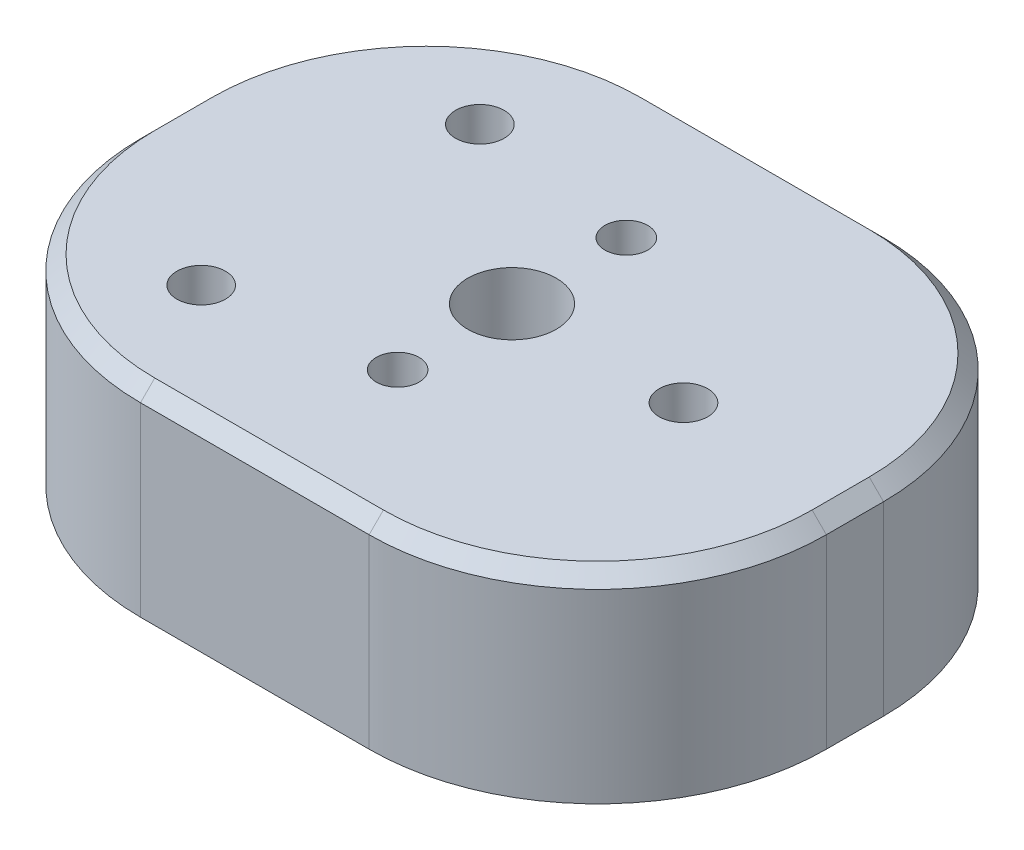
from build123d import *

# Parameters (mm, degrees)
SKETCH1_W           = 48
SKETCH1_H           = 36
SKETCH1_R           = 1.7
BOSS_EXTRUDE1_DEPTH = 14
SKETCH2_R           = 1.5
SKETCH2_R_2         = 3.1
CUT_EXTRUDE3_DEPTH  = 15
SKETCH5_R           = 15
CUT_EXTRUDE4_DEPTH  = 3
SKETCH7_R           = 4.75
CUT_EXTRUDE5_DEPTH  = 6
FILLET1_R           = 16
FILLET2_R           = 16
FILLET3_R           = 0.5
CHAMFER2_SIZE       = 1


with BuildPart() as part:
    # Sketch1 → Boss-Extrude1 (new body)
    with BuildSketch(Plane(origin=(0, 0, 0), x_dir=(1, 0, 0), z_dir=(0, 1, 0))):
        Rectangle(SKETCH1_W, SKETCH1_H)
        with Locations((-12, 9.75)):
            Circle(SKETCH1_R, mode=Mode.SUBTRACT)
        with Locations((-12, -9.75)):
            Circle(SKETCH1_R, mode=Mode.SUBTRACT)
        with Locations((12, 0)):
            Circle(SKETCH1_R, mode=Mode.SUBTRACT)
    extrude(amount=BOSS_EXTRUDE1_DEPTH)

    # Sketch2 → Cut-Extrude3 (cut, through all)
    with BuildSketch(Plane.XZ):
        with Locations((0, 8)):
            Circle(SKETCH2_R)
        with Locations((0, -8)):
            Circle(SKETCH2_R)
        Circle(SKETCH2_R_2)
    extrude(amount=-CUT_EXTRUDE3_DEPTH, mode=Mode.SUBTRACT)

    # Sketch5 → Cut-Extrude4 (cut)
    with BuildSketch(Plane.XZ):
        Circle(SKETCH5_R)
    extrude(amount=-CUT_EXTRUDE4_DEPTH, mode=Mode.SUBTRACT)

    # Sketch7 → Cut-Extrude5 (cut)
    with BuildSketch(Plane.XZ):
        with Locations((12, 0)):
            Circle(SKETCH7_R)
        with Locations((-12, 9.75)):
            Circle(SKETCH7_R)
        with Locations((-12, -9.75)):
            Circle(SKETCH7_R)
    extrude(amount=-CUT_EXTRUDE5_DEPTH, mode=Mode.SUBTRACT)

    # Fillet1
    fillet1_edges = [part.edges().sort_by_distance(p)[0] for p in [
        (24, 7, 18),
        (24, 7, -18),
    ]]
    fillet(fillet1_edges, radius=FILLET1_R)

    # Fillet2
    fillet2_edges = [part.edges().sort_by_distance(p)[0] for p in [
        (-24, 7, 18),
        (-24, 7, -18),
    ]]
    fillet(fillet2_edges, radius=FILLET2_R)

    # Fillet3
    fillet3_edges = [part.edges().sort_by_distance(p)[0] for p in [
        (5.27456542, 0, -14.042042573),
        (5.27456542, 0, 14.042042573),
        (-15, 0, 0),
        (16.13087492, 0, 2.344860848),
        (-15.686541501, 0, 12.745314969),
        (-15.686541501, 0, -12.745314969),
    ]]
    fillet(fillet3_edges, radius=FILLET3_R)

    # Chamfer2
    chamfer2_edges = [part.edges().sort_by_distance(p)[0] for p in [
        (0, 14, -18),
        (19.313708499, 14, -13.313708499),
        (19.313708499, 14, 13.313708499),
        (0, 14, 18),
        (-24, 14, 0),
        (-19.313708499, 14, -13.313708499),
        (-19.313708499, 14, 13.313708499),
        (24, 14, 0),
    ]]
    chamfer(chamfer2_edges, length=CHAMFER2_SIZE)


solid = part.part
